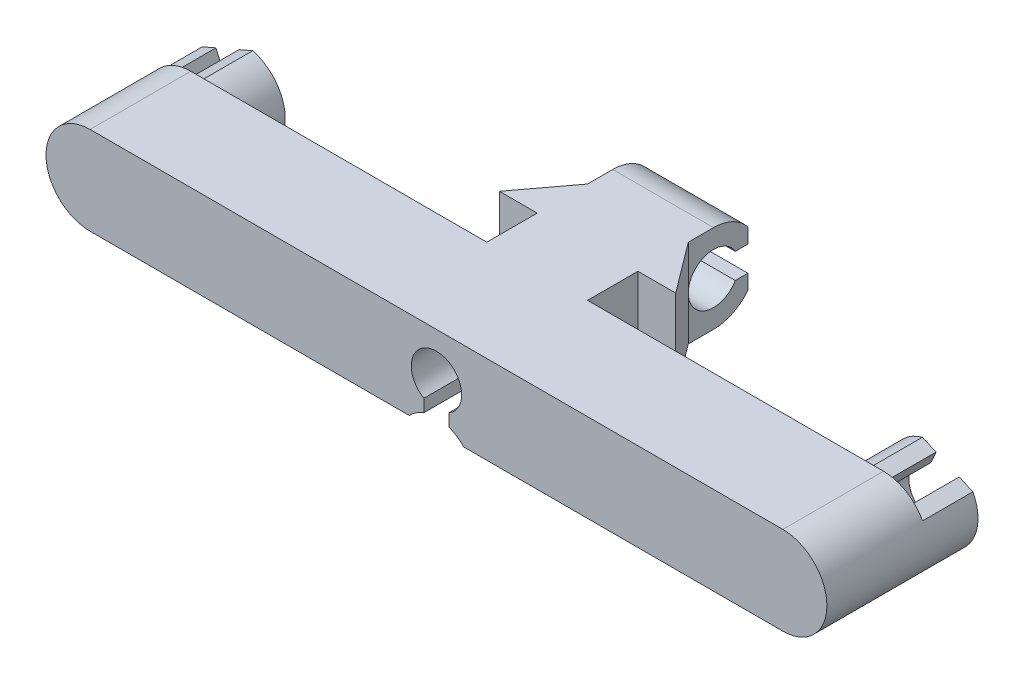
from build123d import *

# Parameters (mm, degrees)
EXTRUDE_1_DEPTH     = 4
SKETCH_2_W          = 4
SKETCH_2_H          = 3.5
EXTRUDE_2_DEPTH     = 2
EXTRUDE_3_DEPTH     = 3.5
EXTRUDE_START       = 2
SKETCH_4_R          = 1.75
EXTRUDE_4_DEPTH     = 2
CUT_EXTRUDE_2_DEPTH = 2
SKETCH_7_W          = 4
SKETCH_7_H          = 3.5
EXTRUDE_5_DEPTH     = 4
CUT_EXTRUDE_4_DEPTH = 4
CUT_EXTRUDE_5_DEPTH = 2


with BuildPart() as part:
    # 草图1 → 凸台-拉伸1 (new body)
    with BuildSketch(Plane.XY):
        with BuildLine():
            Line((-13.7534088, 1.75), (13.7534088, 1.75))
            ThreePointArc((13.7534088, 1.75), (15.5034088, 0), (13.7534088, -1.75))
            Line((13.7534088, -1.75), (-13.7534088, -1.75))
            ThreePointArc((-13.7534088, -1.75), (-15.5034088, 0), (-13.7534088, 1.75))
        make_face()
    extrude(amount=EXTRUDE_1_DEPTH)

    # 草图2 → 凸台-拉伸2 (add)
    with BuildSketch(Plane(origin=(0, 0, 0), x_dir=(-1, 0, 0), z_dir=(0, 0, -1))):
        Rectangle(SKETCH_2_W, SKETCH_2_H)
    extrude(amount=EXTRUDE_2_DEPTH)

    # 草图3 → 凸台-拉伸3 (add)
    with BuildSketch(Plane(origin=(0, 1.75, 0), x_dir=(1, 0, 0), z_dir=(0, 1, 0))):
        Polygon((3.5, 2), (-3.5, 2), (-2, 4), (2, 4), align=None)
    extrude(amount=-EXTRUDE_3_DEPTH)

    # 草图4 → 凸台-拉伸4 (add)
    with BuildSketch(Plane(origin=(0, 0, 0), x_dir=(-1, 0, 0), z_dir=(0, 0, -1)).offset(EXTRUDE_START)):
        with Locations((-13.7534088, 0)):
            Circle(SKETCH_4_R)
        with Locations((13.7534088, 0)):
            Circle(SKETCH_4_R)
    extrude(amount=-EXTRUDE_4_DEPTH)

    # 草图5 → 切除-拉伸2 (cut)
    with BuildSketch(Plane.XY.offset(4)):
        with BuildLine():
            ThreePointArc((1.079530307, -1.75), (0.812765723, -1.523298095), (0.5, -1.366025404))
            Line((0.5, -1.366025404), (0.5, -0.866025404))
            ThreePointArc((0.5, -0.866025404), (0, 1), (-0.5, -0.866025404))
            Line((-0.5, -0.866025404), (-0.5, -1.366025404))
            ThreePointArc((-0.5, -1.366025404), (-0.812765723, -1.523298095), (-1.079530307, -1.75))
            Line((-1.079530307, -1.75), (1.079530307, -1.75))
        make_face()
    extrude(amount=-CUT_EXTRUDE_2_DEPTH, mode=Mode.SUBTRACT)

    # 草图7 → 凸台-拉伸5 (add)
    with BuildSketch(Plane(origin=(0, 0, -4), x_dir=(-1, 0, 0), z_dir=(0, 0, -1))):
        Rectangle(SKETCH_7_W, SKETCH_7_H)
    extrude(amount=EXTRUDE_5_DEPTH)

    # 草图8 → 切除-拉伸4 (cut)
    with BuildSketch(Plane(origin=(2, 0, 0), x_dir=(0, 0, -1), z_dir=(1, 0, 0))):
        with BuildLine():
            ThreePointArc((5.866025404, 0.5), (4, 0), (5.866025404, -0.5))
            Line((5.866025404, -0.5), (6.366025404, -0.5))
            Line((6.366025404, -0.5), (6.366025404, -1.093834812))
            ThreePointArc((6.366025404, -1.093834812), (5.75772326, -1.577452205), (5, -1.75))
            Line((5, -1.75), (8, -1.75))
            Line((8, -1.75), (8, 1.75))
            Line((8, 1.75), (5, 1.75))
            ThreePointArc((5, 1.75), (5.75772326, 1.577452205), (6.366025404, 1.093834812))
            Line((6.366025404, 1.093834812), (6.366025404, 0.5))
            Line((6.366025404, 0.5), (5.866025404, 0.5))
        make_face()
    extrude(amount=-CUT_EXTRUDE_4_DEPTH, mode=Mode.SUBTRACT)

    # 草图6 → 切除-拉伸5 (cut)
    with BuildSketch(Plane(origin=(0, 0, -2), x_dir=(-1, 0, 0), z_dir=(0, 0, -1))):
        with BuildLine():
            Line((13.83870568, 1.45215352), (13.639607299, 0.993503507))
            ThreePointArc((13.639607299, 0.993503507), (13.355212038, -0.917300026), (14.556907325, 0.595306745))
            Line((14.556907325, 0.595306745), (14.756005706, 1.053956758))
            Line((14.756005706, 1.053956758), (15.300730395, 0.817493658))
            ThreePointArc((15.300730395, 0.817493658), (14.450253134, 1.605275046), (13.293980991, 1.68861662))
            Line((13.293980991, 1.68861662), (13.83870568, 1.45215352))
        make_face()
        with BuildLine():
            Line((-14.756005706, 1.053956758), (-14.556907325, 0.595306745))
            ThreePointArc((-14.556907325, 0.595306745), (-13.355212038, -0.917300026), (-13.639607299, 0.993503507))
            Line((-13.639607299, 0.993503507), (-13.83870568, 1.45215352))
            Line((-13.83870568, 1.45215352), (-13.293980991, 1.68861662))
            ThreePointArc((-13.293980991, 1.68861662), (-14.450253134, 1.605275046), (-15.300730395, 0.817493658))
            Line((-15.300730395, 0.817493658), (-14.756005706, 1.053956758))
        make_face()
    extrude(amount=-CUT_EXTRUDE_5_DEPTH, mode=Mode.SUBTRACT)


solid = part.part
